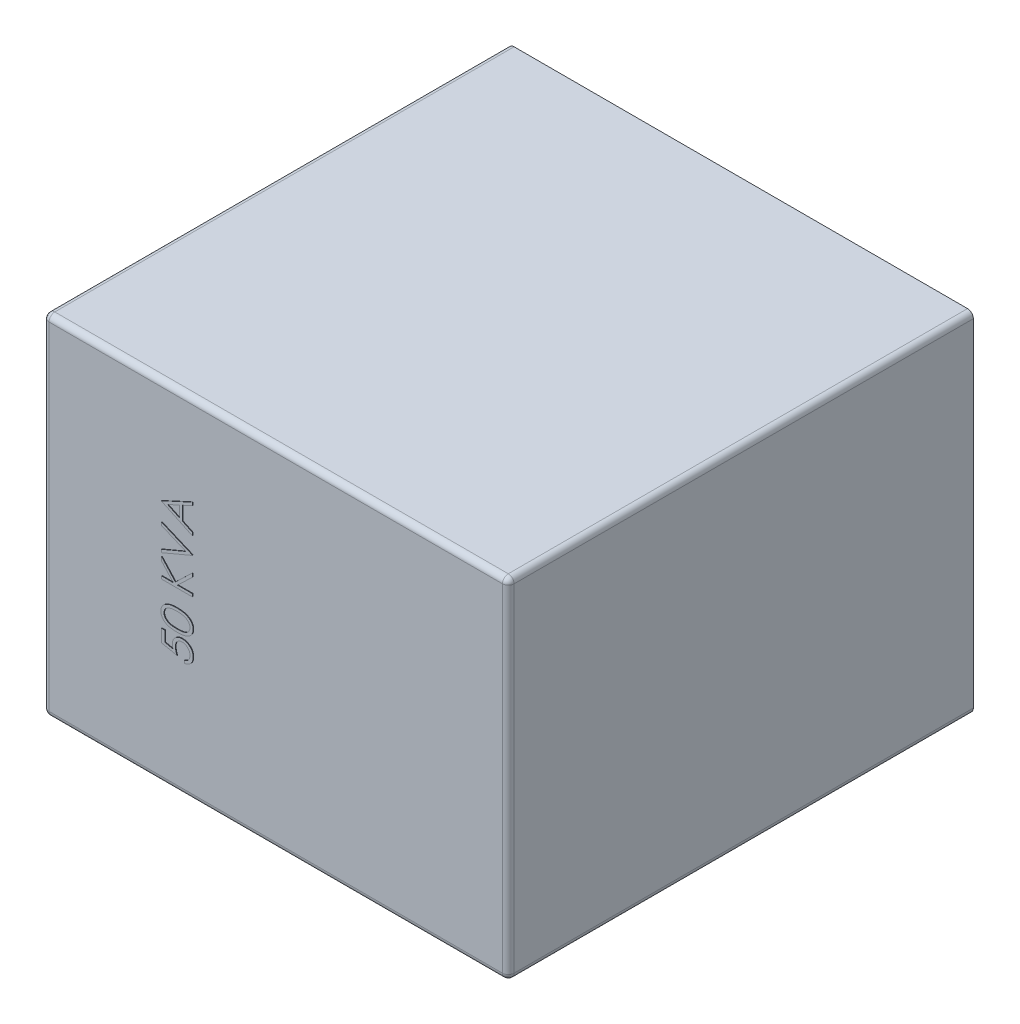
from build123d import *

# Parameters (mm, degrees)
CROQUIS1_W              = 800
CROQUIS1_H              = 600
SALIENTE_EXTRUIR1_DEPTH = 800
SALIENTE_EXTRUIR2_DEPTH = 1
REDONDEO1_R             = 10
CROQUIS3_W              = 215.98914201
CROQUIS3_H              = 367.856507486
CROQUIS3_W_2            = 212.116523425
CROQUIS3_H_2            = 361.260953958
SALIENTE_EXTRUIR3_DEPTH = 100
CROQUIS4_W              = 55.062185653
CROQUIS4_H              = 10.634875111
CROQUIS4_H_2            = 9.305515721
CROQUIS4_H_3            = 9.305515722
SALIENTE_EXTRUIR4_DEPTH = 100


with BuildPart() as part:
    # Croquis1 → Saliente-Extruir1 (new body)
    with BuildSketch(Plane.XY):
        Rectangle(CROQUIS1_W, CROQUIS1_H)
    extrude(amount=SALIENTE_EXTRUIR1_DEPTH)

    # Croquis2 → Saliente-Extruir2 (add)
    with BuildSketch(Plane.XY.offset(800)):
        with BuildLine():
            Line((-195.325237983, -68.438181469), (-189.897887555, -68.438181469))
            Line((-189.897887555, -68.438181469), (-189.897887555, -86.437480347))
            Line((-189.897887555, -86.437480347), (-175.979701791, -89.28895938))
            add(Edge.make_bspline(
                [(-175.979701791, -89.28895938), (-176.134373758, -88.728709851), (-176.43402623, -87.643314997), (-176.766732521, -86.041302814), (-176.967293402, -84.520444499), (-176.994678692, -83.533543066), (-177.00793029, -83.055986624)],
                knots=[0, 0, 0, 0, 0.001743257, 0.003377285, 0.004905088, 0.00633754, 0.00633754, 0.00633754, 0.00633754], degree=3))
            add(Edge.make_bspline(
                [(-177.00793029, -83.055986624), (-176.99556293, -82.464969234), (-176.97124561, -81.30288138), (-176.723880396, -79.605249622), (-176.365592039, -77.9765149), (-175.813580993, -76.440725336), (-175.139477056, -74.973583196), (-174.290428426, -73.600284858), (-173.299166245, -72.301556035), (-172.170795716, -71.08637287), (-170.916056583, -69.989138255), (-169.56138199, -69.035677537), (-168.136333208, -68.203483201), (-166.607510017, -67.5544463), (-165.00374654, -67.024768878), (-163.306529914, -66.675498263), (-161.530927645, -66.442200622), (-160.316784925, -66.416189203), (-159.697650509, -66.402925058)],
                knots=[0, 0, 0, 0, 0.001771804, 0.003483808, 0.005137216, 0.006766561, 0.00836945, 0.009972935, 0.01159907, 0.01326416, 0.014939443, 0.016589449, 0.0182277, 0.019879885, 0.021562696, 0.023286246, 0.025070437, 0.026926971, 0.026926971, 0.026926971, 0.026926971], degree=3))
            add(Edge.make_bspline(
                [(-159.697650509, -66.402925058), (-159.266424396, -66.412989421), (-158.409799817, -66.432982135), (-157.137580136, -66.534427981), (-155.8924795, -66.730497722), (-154.676780588, -66.990547115), (-153.489344808, -67.337700211), (-152.323523763, -67.743758851), (-151.192083106, -68.248462874), (-150.090025725, -68.80798366), (-149.029964294, -69.427547477), (-148.037315708, -70.124233228), (-147.089427508, -70.848129858), (-146.214450529, -71.639120573), (-145.40899088, -72.488212234), (-144.669066568, -73.390680415), (-143.98139818, -74.338339588), (-143.374102562, -75.346115286), (-142.815255369, -76.391480554), (-142.356793036, -77.489550895), (-141.946907489, -78.615325537), (-141.620192062, -79.785008839), (-141.36418795, -80.995950988), (-141.190309826, -82.250148194), (-141.063666068, -83.541022608), (-141.05573829, -84.41603768), (-141.051733709, -84.85803657)],
                knots=[0, 0, 0, 0, 0.001293931, 0.002570375, 0.003825201, 0.005072707, 0.006297259, 0.007534409, 0.008773239, 0.01001057, 0.011241346, 0.012452798, 0.013646544, 0.014817384, 0.015987073, 0.017154309, 0.018316335, 0.01949621, 0.020681596, 0.021868877, 0.023062528, 0.02427398, 0.025508903, 0.026772651, 0.028071133, 0.029396552, 0.029396552, 0.029396552, 0.029396552], degree=3))
            add(Edge.make_bspline(
                [(-141.051733709, -84.85803657), (-141.062206611, -85.385287524), (-141.082810809, -86.42259149), (-141.297380351, -87.942558383), (-141.606725607, -89.404091232), (-142.065037363, -90.800926115), (-142.66516398, -92.127237439), (-143.378205174, -93.402017675), (-144.227069803, -94.609466494), (-145.203993596, -95.741328916), (-146.277427019, -96.781761386), (-147.431157662, -97.725233213), (-148.666654865, -98.554719156), (-149.979901155, -99.273228135), (-151.368567177, -99.885332299), (-152.836931727, -100.366396298), (-154.377574447, -100.754614409), (-155.438227098, -100.918860931), (-155.976947384, -101.002284033)],
                knots=[0, 0, 0, 0, 0.001580724, 0.003109887, 0.004596538, 0.006058073, 0.007510003, 0.008957632, 0.01043393, 0.011929774, 0.013436545, 0.0149133, 0.016395068, 0.017894176, 0.019398857, 0.020940827, 0.022524533, 0.02415918, 0.02415918, 0.02415918, 0.02415918], degree=3))
            Line((-155.976947384, -101.002284033), (-155.976947384, -96.253352409))
            add(Edge.make_bspline(
                [(-155.976947384, -96.253352409), (-155.472274671, -96.136577083), (-154.502265694, -95.912128421), (-153.140264826, -95.418187752), (-151.926126996, -94.820124102), (-150.852428775, -94.092384818), (-149.899516345, -93.248841813), (-149.059335589, -92.268266665), (-148.300422947, -91.175173428), (-147.666745806, -89.95986842), (-147.13295827, -88.675232231), (-146.752029949, -87.338359197), (-146.521445846, -85.96848952), (-146.493257851, -85.046188011), (-146.479084136, -84.582428931)],
                knots=[0, 0, 0, 0, 0.001552862, 0.002984686, 0.004335756, 0.005602923, 0.006864403, 0.008141815, 0.009467912, 0.010847824, 0.012245456, 0.013634539, 0.015009516, 0.016400136, 0.016400136, 0.016400136, 0.016400136], degree=3))
            add(Edge.make_bspline(
                [(-146.479084136, -84.582428931), (-146.491597347, -84.129524207), (-146.516235961, -83.237751099), (-146.702812696, -81.924694487), (-146.997710148, -80.660692909), (-147.410844589, -79.44350259), (-147.957397231, -78.279104573), (-148.628805649, -77.169145194), (-149.408318815, -76.097812102), (-150.29927391, -75.093301173), (-151.281664583, -74.173515137), (-152.332067651, -73.360761107), (-153.452651367, -72.68378014), (-154.623969643, -72.113275471), (-155.858872181, -71.680065119), (-157.151568372, -71.371016886), (-158.505252042, -71.189542086), (-159.428561839, -71.164577815), (-159.899056092, -71.151856682)],
                knots=[0, 0, 0, 0, 0.001358327, 0.002674558, 0.003970441, 0.005247634, 0.006523285, 0.007821291, 0.009133717, 0.010492913, 0.01184286, 0.013165859, 0.014469351, 0.015763672, 0.017067853, 0.018386812, 0.019745057, 0.02115633, 0.02115633, 0.02115633, 0.02115633], degree=3))
            add(Edge.make_bspline(
                [(-159.899056092, -71.151856682), (-160.323584896, -71.161509773), (-161.151035422, -71.180324645), (-162.365860752, -71.343203722), (-163.517157823, -71.615290656), (-164.609936116, -72.002687171), (-165.640701767, -72.486170409), (-166.607183246, -73.093198274), (-167.518468026, -73.797922982), (-168.351104909, -74.620673114), (-169.120800153, -75.515654943), (-169.774565804, -76.505856173), (-170.330540289, -77.564842114), (-170.786063108, -78.694575217), (-171.148921912, -79.896447066), (-171.399698578, -81.171104987), (-171.549759545, -82.518839487), (-171.570116077, -83.440733156), (-171.580579863, -83.914610422)],
                knots=[0, 0, 0, 0, 0.001273139, 0.002481479, 0.003669327, 0.004815925, 0.005953914, 0.007077545, 0.008233172, 0.009402572, 0.010583399, 0.011768216, 0.012953602, 0.014166166, 0.015417046, 0.016714273, 0.018058129, 0.019479557, 0.019479557, 0.019479557, 0.019479557], degree=3))
            add(Edge.make_bspline(
                [(-171.580579863, -83.914610422), (-171.571801878, -84.324773988), (-171.553677565, -85.171657694), (-171.420229339, -86.470729003), (-171.204944768, -87.835853862), (-170.90881936, -89.261799211), (-170.52130189, -90.75284737), (-170.056927893, -92.305851762), (-169.501726245, -93.924077697), (-169.082441585, -95.014429006), (-168.866904649, -95.574933605)],
                knots=[0, 0, 0, 0, 0.001230365, 0.002540391, 0.003913692, 0.005375188, 0.006907508, 0.008534057, 0.01023698, 0.012038438, 0.012038438, 0.012038438, 0.012038438], degree=3))
            Line((-168.866904649, -95.574933605), (-195.325237983, -90.147583178))
            Line((-195.325237983, -90.147583178), (-195.325237983, -68.438181469))
        make_face()
        with BuildLine():
            add(Edge.make_bspline(
                [(-168.845704062, -60.975574631), (-169.693843138, -60.970615309), (-171.341365519, -60.960981754), (-173.742038083, -60.85381158), (-175.994175789, -60.675779622), (-178.097886419, -60.431797903), (-180.053713134, -60.134890379), (-181.856428981, -59.738537074), (-183.514378208, -59.287796276), (-185.032964935, -58.76539491), (-186.432656414, -58.175941122), (-187.739306294, -57.534359816), (-188.951035748, -56.815281085), (-190.086833928, -56.059478775), (-191.129353991, -55.237529593), (-192.090607744, -54.367057694), (-192.962488751, -53.430653519), (-193.745594081, -52.437399333), (-194.432263187, -51.394026882), (-195.040829758, -50.329047625), (-195.542102805, -49.22343276), (-195.952157955, -48.091737082), (-196.286895436, -46.931575406), (-196.51682579, -45.743243908), (-196.661240347, -44.52398795), (-196.675064617, -43.701041319), (-196.682075589, -43.283684273)],
                knots=[0, 0, 0, 0, 0.002544269, 0.00494228, 0.007207322, 0.009320293, 0.011294824, 0.013139062, 0.014854378, 0.016446717, 0.01795278, 0.01940815, 0.020809836, 0.022176946, 0.023498076, 0.024788702, 0.026063737, 0.02733188, 0.02857844, 0.0298078, 0.031007929, 0.032215153, 0.033416406, 0.034626326, 0.035842591, 0.037094145, 0.037094145, 0.037094145, 0.037094145], degree=3))
            add(Edge.make_bspline(
                [(-196.682075589, -43.283684273), (-196.676235859, -42.862634253), (-196.66461685, -42.024892903), (-196.501072316, -40.790798399), (-196.289980653, -39.578199717), (-195.951424387, -38.405494373), (-195.546297909, -37.250508762), (-195.011739956, -36.141965062), (-194.430366672, -35.040725814), (-193.721140169, -33.996818845), (-192.937328171, -32.979054122), (-192.047501169, -32.025005957), (-191.076285224, -31.110286329), (-190.002019381, -30.269443839), (-188.84117532, -29.466441149), (-187.584021822, -28.731761048), (-186.233344915, -28.050123535), (-184.79540614, -27.40871563), (-183.23179592, -26.847821355), (-181.552266903, -26.349141507), (-179.741610147, -25.940388994), (-177.80991216, -25.602357852), (-175.747603331, -25.339981339), (-173.55886214, -25.149028148), (-171.242319277, -25.048125985), (-169.658479871, -25.029127478), (-168.845704062, -25.01937805)],
                knots=[0, 0, 0, 0, 0.001262147, 0.002511229, 0.003729571, 0.004951229, 0.006168418, 0.007396681, 0.008639449, 0.009900706, 0.011177195, 0.012489963, 0.013809944, 0.015175738, 0.016578265, 0.018041759, 0.019539817, 0.021115521, 0.022761983, 0.024519523, 0.026368385, 0.028327232, 0.030400694, 0.032603235, 0.034916529, 0.037354966, 0.037354966, 0.037354966, 0.037354966], degree=3))
            add(Edge.make_bspline(
                [(-168.845704062, -25.01937805), (-168.036480635, -25.02934197), (-166.456212329, -25.048799721), (-164.149984135, -25.146864078), (-161.973040735, -25.344645443), (-159.92306118, -25.588435866), (-157.999095016, -25.930245149), (-156.202395909, -26.342097072), (-154.52660272, -26.811341086), (-152.983722286, -27.38084358), (-151.548278769, -28.007322197), (-150.207533302, -28.68822826), (-148.950711806, -29.418762443), (-147.786805835, -30.209721957), (-146.716851919, -31.06439545), (-145.742304878, -31.97847394), (-144.8468182, -32.940852065), (-144.054370921, -33.964550177), (-143.339744723, -35.0181805), (-142.737273731, -36.119531628), (-142.215267962, -37.240417023), (-141.788480098, -38.392027654), (-141.457501123, -39.572585504), (-141.229971105, -40.786015309), (-141.070034978, -42.025067056), (-141.057855255, -42.862692505), (-141.051733709, -43.283684273)],
                knots=[0, 0, 0, 0, 0.002427838, 0.004741132, 0.006922553, 0.008984167, 0.010932574, 0.012781437, 0.014512696, 0.016149197, 0.017710934, 0.019208992, 0.020657979, 0.022069252, 0.023426752, 0.024761716, 0.026074484, 0.02736585, 0.028641811, 0.029889677, 0.031127554, 0.032348384, 0.033570042, 0.034800772, 0.036049854, 0.037312001, 0.037312001, 0.037312001, 0.037312001], degree=3))
            add(Edge.make_bspline(
                [(-141.051733709, -43.283684273), (-141.05878456, -43.701032187), (-141.072687461, -44.523960811), (-141.216526018, -45.743348675), (-141.447779468, -46.926904652), (-141.771578093, -48.080469196), (-142.167921573, -49.209960375), (-142.684292282, -50.299988246), (-143.278987683, -51.362668508), (-143.956245167, -52.395181606), (-144.732205449, -53.378066086), (-145.590331001, -54.317080641), (-146.552627065, -55.187767197), (-147.603943312, -56.00258934), (-148.741431358, -56.766381839), (-149.965854562, -57.47924678), (-151.279303645, -58.134282536), (-152.690057011, -58.733807037), (-154.219421978, -59.2653524), (-155.881597463, -59.733060419), (-157.693466231, -60.106604451), (-159.645829051, -60.423240761), (-161.742652981, -60.676965586), (-163.984696623, -60.853737651), (-166.367702524, -60.960900393), (-168.004630452, -60.970593959), (-168.845704062, -60.975574631)],
                knots=[0, 0, 0, 0, 0.001251553, 0.002467818, 0.003677739, 0.004865918, 0.006059569, 0.007264138, 0.008479063, 0.009710934, 0.010964191, 0.012232024, 0.01352265, 0.014852132, 0.016219241, 0.017630076, 0.019099661, 0.020619611, 0.022225442, 0.02395381, 0.025795823, 0.027772031, 0.029886252, 0.032130162, 0.034517582, 0.037040652, 0.037040652, 0.037040652, 0.037040652], degree=3))
        make_face()
        with BuildLine():
            add(Edge.make_bspline(
                [(-168.866904649, -56.226643007), (-168.160111672, -56.224797482), (-166.788365288, -56.221215679), (-164.798504737, -56.130351601), (-162.939443464, -56.00387807), (-161.211907045, -55.844767091), (-159.621933166, -55.606475774), (-158.16291173, -55.336119706), (-156.83754336, -55.011844102), (-155.634245907, -54.626275988), (-154.535980191, -54.18707638), (-153.513473548, -53.70838954), (-152.554607361, -53.189586922), (-151.661707982, -52.620034205), (-150.845690123, -51.988470926), (-150.085869599, -51.32417644), (-149.408672295, -50.597224643), (-148.596344572, -49.5917961), (-147.756961762, -48.264375917), (-147.026010816, -46.59190636), (-146.566658041, -44.873346039), (-146.508241595, -43.706892825), (-146.479084136, -43.124679866)],
                knots=[0, 0, 0, 0, 0.002120165, 0.004114823, 0.005974231, 0.007710383, 0.009317438, 0.010795599, 0.012160776, 0.013407832, 0.014582983, 0.015706864, 0.016793123, 0.017851667, 0.01887995, 0.019886141, 0.020876006, 0.021856061, 0.023761757, 0.025565676, 0.027316523, 0.029061294, 0.029061294, 0.029061294, 0.029061294], degree=3))
            add(Edge.make_bspline(
                [(-146.479084136, -43.124679866), (-146.504614976, -42.539096702), (-146.555586091, -41.37000756), (-147.000441895, -39.653025909), (-147.723636163, -37.999962364), (-148.549868473, -36.695382139), (-149.341754187, -35.705634866), (-150.016134468, -34.996235623), (-150.771461495, -34.345194871), (-151.586355876, -33.727697037), (-152.476455007, -33.161352757), (-153.437459689, -32.646350196), (-154.472043944, -32.176399684), (-155.194276869, -31.908655761), (-155.563535926, -31.771765203)],
                knots=[0, 0, 0, 0, 0.001754469, 0.003502714, 0.005282964, 0.007150452, 0.008115602, 0.009082788, 0.010081975, 0.011103846, 0.012147746, 0.013243326, 0.014372394, 0.015553554, 0.015553554, 0.015553554, 0.015553554], degree=3))
            add(Edge.make_bspline(
                [(-155.563535926, -31.771765203), (-156.035699844, -31.612232523), (-156.994395089, -31.288312766), (-158.481559829, -30.870849036), (-160.041887331, -30.54207931), (-161.666052786, -30.246299852), (-163.36603398, -30.044414364), (-165.136570975, -29.881917663), (-166.978998714, -29.786203706), (-168.230780128, -29.774339017), (-168.866904649, -29.768309674)],
                knots=[0, 0, 0, 0, 0.001495055, 0.003035603, 0.004630339, 0.006277244, 0.00798649, 0.009763866, 0.011610783, 0.0135191, 0.0135191, 0.0135191, 0.0135191], degree=3))
            add(Edge.make_bspline(
                [(-168.866904649, -29.768309674), (-169.502926281, -29.776628011), (-170.747120559, -29.792900457), (-172.56924067, -29.855100033), (-174.299884201, -30.015718359), (-175.946506813, -30.194109809), (-177.499993568, -30.457139189), (-178.973349251, -30.740739484), (-180.348321602, -31.121757396), (-181.646435219, -31.528760202), (-182.852950271, -31.994579028), (-183.973462323, -32.50736994), (-185.013484143, -33.054947901), (-185.969802342, -33.649976671), (-186.847964003, -34.284168096), (-187.627762673, -34.98026071), (-188.347131265, -35.694047481), (-189.153596574, -36.709202732), (-189.982372805, -38.027412712), (-190.724315706, -39.679025906), (-191.163417533, -41.388374362), (-191.224311231, -42.546328677), (-191.254725162, -43.124679866)],
                knots=[0, 0, 0, 0, 0.001908318, 0.003733078, 0.005467287, 0.007121375, 0.008700249, 0.010192897, 0.011620005, 0.012977712, 0.014273031, 0.015496849, 0.016672861, 0.017796492, 0.018873557, 0.019917619, 0.020929544, 0.021909599, 0.023800674, 0.02558518, 0.027323143, 0.029057352, 0.029057352, 0.029057352, 0.029057352], degree=3))
            add(Edge.make_bspline(
                [(-191.254725162, -43.124679866), (-191.224235564, -43.710036057), (-191.163200823, -44.881814818), (-190.726346417, -46.60941752), (-189.984543587, -48.272188357), (-189.155193306, -49.594745309), (-188.350223337, -50.597568128), (-187.665101211, -51.309194721), (-186.923428653, -51.982702064), (-186.100171787, -52.597911084), (-185.210418544, -53.164086519), (-184.263952167, -53.702939005), (-183.239534983, -54.17522454), (-182.142130452, -54.615834174), (-180.938766814, -55.002045409), (-179.608602803, -55.322615804), (-178.146097123, -55.61445724), (-176.544505983, -55.824630643), (-174.816600859, -56.009702283), (-172.952785357, -56.12896315), (-170.956091801, -56.22163193), (-169.577248225, -56.224939193), (-168.866904649, -56.226643007)],
                knots=[0, 0, 0, 0, 0.001755333, 0.003513864, 0.005308071, 0.007199147, 0.008179202, 0.009161375, 0.010159661, 0.011181532, 0.012240076, 0.013322189, 0.01444607, 0.015621222, 0.016868278, 0.018233454, 0.01972403, 0.02134008, 0.023077299, 0.024936707, 0.026941956, 0.029072721, 0.029072721, 0.029072721, 0.029072721], degree=3))
        make_face(mode=Mode.SUBTRACT)
        Polygon((-195.325237983, 4.831049301), (-195.325237983, 9.579980924), (-175.174079462, 9.579980924), (-195.325237983, 31.639192329), (-195.325237983, 38.41278007), (-171.580579863, 12.41025937), (-142.408571316, 40.44803648), (-142.408571316, 34.119661079), (-167.944679088, 9.579980924), (-142.408571316, 9.579980924), (-142.408571316, 4.831049301), align=None)
        Polygon((-195.325237983, 44.179339899), (-195.325237983, 49.267480924), (-153.62368216, 66.906369813), (-195.325237983, 84.545258702), (-195.325237983, 89.633399728), (-142.408571316, 67.245579215), (-142.408571316, 66.567160412), align=None)
        Polygon((-195.325237983, 121.519083489), (-142.408571316, 145.942160412), (-142.408571316, 140.779817329), (-159.369041401, 132.956800502), (-159.369041401, 108.968335625), (-142.408571316, 100.922712629), (-142.408571316, 95.739168959), (-195.325237983, 120.840664685), align=None)
        Polygon((-185.011152112, 121.126872618), (-164.796391829, 111.54420702), (-164.796391829, 130.455131165), align=None, mode=Mode.SUBTRACT)
    extrude(amount=SALIENTE_EXTRUIR2_DEPTH)

    # Redondeo1
    redondeo1_edges = [part.edges().sort_by_distance(p)[0] for p in [
        (-400, 0, 800),
        (0, -300, 800),
        (400, 0, 800),
        (0, 300, 800),
        (400, -300, 400),
        (-400, -300, 400),
        (-400, 300, 400),
        (400, 300, 400),
    ]]
    fillet(redondeo1_edges, radius=REDONDEO1_R)

    # Croquis3 → Saliente-Extruir3 (add)
    with BuildSketch(Plane.ZY.offset(400)):
        with Locations((571.772639953, 0)):
            Rectangle(CROQUIS3_W, CROQUIS3_H)
        with Locations((571.772639954, 0)):
            Rectangle(CROQUIS3_W_2, CROQUIS3_H_2, mode=Mode.SUBTRACT)
    extrude(amount=SALIENTE_EXTRUIR3_DEPTH)

    # Croquis4 → Saliente-Extruir4 (add)
    with BuildSketch(Plane.ZY.offset(400)):
        with Locations((571.772639953, 128.506178023)):
            Rectangle(CROQUIS4_W, CROQUIS4_H)
        with Locations((571.772639953, 54.726731945)):
            Rectangle(CROQUIS4_W, CROQUIS4_H_2)
        with Locations((571.772639953, -56.939456714)):
            Rectangle(CROQUIS4_W, CROQUIS4_H)
        with Locations((571.772639953, -128.724863708)):
            Rectangle(CROQUIS4_W, CROQUIS4_H_3)
    extrude(amount=SALIENTE_EXTRUIR4_DEPTH)


solid = part.part
